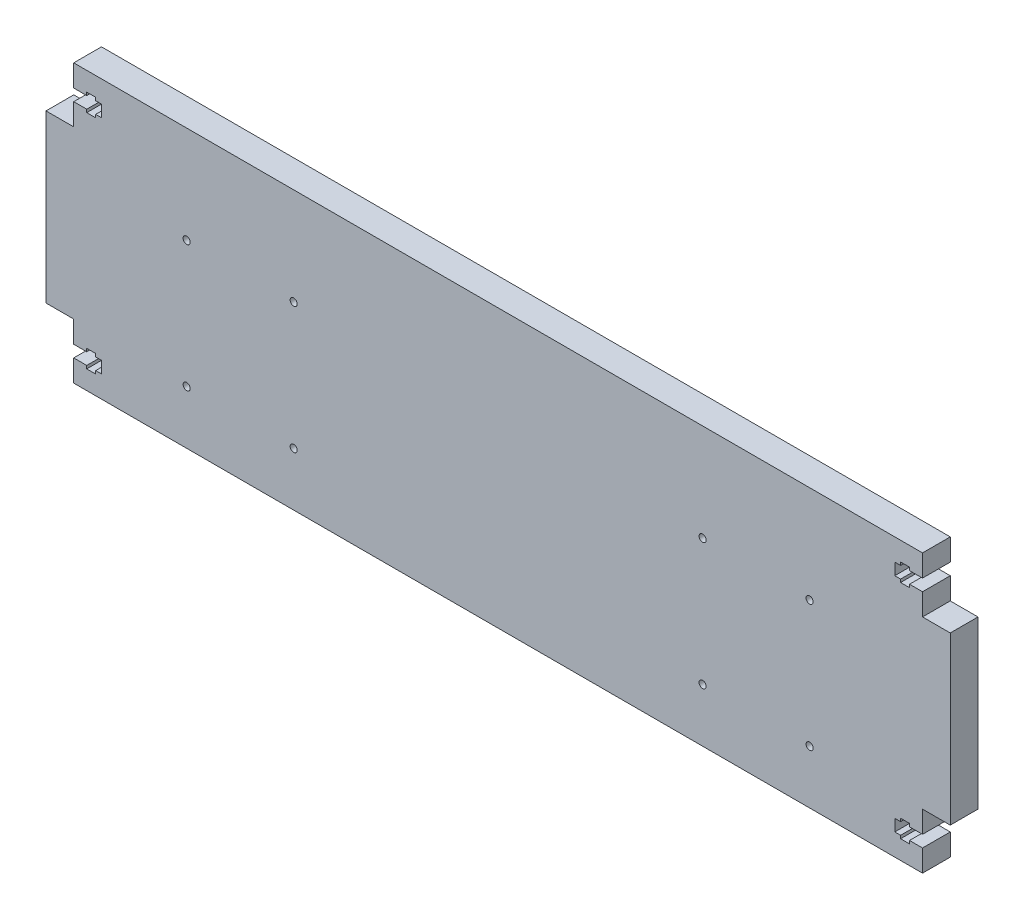
from build123d import *

# Parameters (mm, degrees)
BOSS_EXTRUDE1_DEPTH     = 12.7
M5_SHAFT_REACH          = 14.7
SKETCH2_W               = 12.7
SKETCH2_H               = 5.400000122
M5_START                = -12.7
SKETCH3_W               = 4.1
SKETCH3_H               = 8.15
M5_NUT_DEPTH            = 12.7
RASBERRY_PI_HOLES_REACH = 14.7
SKETCH5_R               = 1.625


with BuildPart() as part:
    # Sketch1 → Boss-Extrude1 (new body)
    with BuildSketch(Plane.XY):
        Polygon((194.31, -63.5), (-194.31, -63.5), (-194.31, -38.1), (-207.01, -38.1), (-207.01, 38.1), (-194.31, 38.1), (-194.31, 63.5), (194.31, 63.5), (194.31, 38.1), (207.01, 38.1), (207.01, -38.1), (194.31, -38.1), align=None)
    extrude(amount=BOSS_EXTRUDE1_DEPTH)

    # Sketch2 → m5 shaft (cut, up to next)
    with BuildSketch(Plane.XY.offset(12.7), mode=Mode.PRIVATE) as m5_shaft_sk1:
        with Locations((-187.96, 50.8)):
            Rectangle(SKETCH2_W, SKETCH2_H)
    m5_shaft_tool1 = extrude(m5_shaft_sk1.sketch, amount=-M5_SHAFT_REACH, mode=Mode.PRIVATE) & part.part
    add(m5_shaft_tool1.solids().sort_by_distance((-187.96, 50.8, 12.7))[0], mode=Mode.SUBTRACT)
    # Sketch2 → m5 shaft (cut, up to next)
    with BuildSketch(Plane.XY.offset(12.7), mode=Mode.PRIVATE) as m5_shaft_sk2:
        with Locations((-187.96, -50.8)):
            Rectangle(SKETCH2_W, SKETCH2_H)
    m5_shaft_tool2 = extrude(m5_shaft_sk2.sketch, amount=-M5_SHAFT_REACH, mode=Mode.PRIVATE) & part.part
    add(m5_shaft_tool2.solids().sort_by_distance((-187.96, -50.8, 12.7))[0], mode=Mode.SUBTRACT)
    # Sketch2 → m5 shaft (cut, up to next)
    with BuildSketch(Plane.XY.offset(12.7), mode=Mode.PRIVATE) as m5_shaft_sk3:
        with Locations((187.96, -50.8)):
            Rectangle(SKETCH2_W, SKETCH2_H)
    m5_shaft_tool3 = extrude(m5_shaft_sk3.sketch, amount=-M5_SHAFT_REACH, mode=Mode.PRIVATE) & part.part
    add(m5_shaft_tool3.solids().sort_by_distance((187.96, -50.8, 12.7))[0], mode=Mode.SUBTRACT)
    # Sketch2 → m5 shaft (cut, up to next)
    with BuildSketch(Plane.XY.offset(12.7), mode=Mode.PRIVATE) as m5_shaft_sk4:
        with Locations((187.96, 50.8)):
            Rectangle(SKETCH2_W, SKETCH2_H)
    m5_shaft_tool4 = extrude(m5_shaft_sk4.sketch, amount=-M5_SHAFT_REACH, mode=Mode.PRIVATE) & part.part
    add(m5_shaft_tool4.solids().sort_by_distance((187.96, 50.8, 12.7))[0], mode=Mode.SUBTRACT)

    # Sketch3 → m5 nut (cut)
    with BuildSketch(Plane.XY.offset(12.7).offset(M5_START)):
        with Locations((-186.31, 50.8)):
            Rectangle(SKETCH3_W, SKETCH3_H)
        with Locations((-186.31, -50.8)):
            Rectangle(SKETCH3_W, SKETCH3_H)
        with Locations((186.31, -50.8)):
            Rectangle(SKETCH3_W, SKETCH3_H)
        with Locations((186.31, 50.8)):
            Rectangle(SKETCH3_W, SKETCH3_H)
    extrude(amount=M5_NUT_DEPTH, mode=Mode.SUBTRACT)

    # Sketch5 → rasberry pi holes (cut, up to next)
    with BuildSketch(Plane.XY.offset(12.7), mode=Mode.PRIVATE) as rasberry_pi_holes_sk1:
        with Locations((-142.61, 19)):
            Circle(SKETCH5_R)
    rasberry_pi_holes_tool1 = extrude(rasberry_pi_holes_sk1.sketch, amount=-RASBERRY_PI_HOLES_REACH, mode=Mode.PRIVATE) & part.part
    add(rasberry_pi_holes_tool1.solids().sort_by_distance((-142.61, 19, 12.7))[0], mode=Mode.SUBTRACT)
    # Sketch5 → rasberry pi holes (cut, up to next)
    with BuildSketch(Plane.XY.offset(12.7), mode=Mode.PRIVATE) as rasberry_pi_holes_sk2:
        with Locations((-93.61, 19)):
            Circle(SKETCH5_R)
    rasberry_pi_holes_tool2 = extrude(rasberry_pi_holes_sk2.sketch, amount=-RASBERRY_PI_HOLES_REACH, mode=Mode.PRIVATE) & part.part
    add(rasberry_pi_holes_tool2.solids().sort_by_distance((-93.61, 19, 12.7))[0], mode=Mode.SUBTRACT)
    # Sketch5 → rasberry pi holes (cut, up to next)
    with BuildSketch(Plane.XY.offset(12.7), mode=Mode.PRIVATE) as rasberry_pi_holes_sk3:
        with Locations((-93.61, -39)):
            Circle(SKETCH5_R)
    rasberry_pi_holes_tool3 = extrude(rasberry_pi_holes_sk3.sketch, amount=-RASBERRY_PI_HOLES_REACH, mode=Mode.PRIVATE) & part.part
    add(rasberry_pi_holes_tool3.solids().sort_by_distance((-93.61, -39, 12.7))[0], mode=Mode.SUBTRACT)
    # Sketch5 → rasberry pi holes (cut, up to next)
    with BuildSketch(Plane.XY.offset(12.7), mode=Mode.PRIVATE) as rasberry_pi_holes_sk4:
        with Locations((-142.61, -39)):
            Circle(SKETCH5_R)
    rasberry_pi_holes_tool4 = extrude(rasberry_pi_holes_sk4.sketch, amount=-RASBERRY_PI_HOLES_REACH, mode=Mode.PRIVATE) & part.part
    add(rasberry_pi_holes_tool4.solids().sort_by_distance((-142.61, -39, 12.7))[0], mode=Mode.SUBTRACT)
    # Sketch5 → rasberry pi holes (cut, up to next)
    with BuildSketch(Plane.XY.offset(12.7), mode=Mode.PRIVATE) as rasberry_pi_holes_sk5:
        with Locations((142.61, -39)):
            Circle(SKETCH5_R)
    rasberry_pi_holes_tool5 = extrude(rasberry_pi_holes_sk5.sketch, amount=-RASBERRY_PI_HOLES_REACH, mode=Mode.PRIVATE) & part.part
    add(rasberry_pi_holes_tool5.solids().sort_by_distance((142.61, -39, 12.7))[0], mode=Mode.SUBTRACT)
    # Sketch5 → rasberry pi holes (cut, up to next)
    with BuildSketch(Plane.XY.offset(12.7), mode=Mode.PRIVATE) as rasberry_pi_holes_sk6:
        with Locations((93.61, -39)):
            Circle(SKETCH5_R)
    rasberry_pi_holes_tool6 = extrude(rasberry_pi_holes_sk6.sketch, amount=-RASBERRY_PI_HOLES_REACH, mode=Mode.PRIVATE) & part.part
    add(rasberry_pi_holes_tool6.solids().sort_by_distance((93.61, -39, 12.7))[0], mode=Mode.SUBTRACT)
    # Sketch5 → rasberry pi holes (cut, up to next)
    with BuildSketch(Plane.XY.offset(12.7), mode=Mode.PRIVATE) as rasberry_pi_holes_sk7:
        with Locations((93.61, 19)):
            Circle(SKETCH5_R)
    rasberry_pi_holes_tool7 = extrude(rasberry_pi_holes_sk7.sketch, amount=-RASBERRY_PI_HOLES_REACH, mode=Mode.PRIVATE) & part.part
    add(rasberry_pi_holes_tool7.solids().sort_by_distance((93.61, 19, 12.7))[0], mode=Mode.SUBTRACT)
    # Sketch5 → rasberry pi holes (cut, up to next)
    with BuildSketch(Plane.XY.offset(12.7), mode=Mode.PRIVATE) as rasberry_pi_holes_sk8:
        with Locations((142.61, 19)):
            Circle(SKETCH5_R)
    rasberry_pi_holes_tool8 = extrude(rasberry_pi_holes_sk8.sketch, amount=-RASBERRY_PI_HOLES_REACH, mode=Mode.PRIVATE) & part.part
    add(rasberry_pi_holes_tool8.solids().sort_by_distance((142.61, 19, 12.7))[0], mode=Mode.SUBTRACT)


solid = part.part
